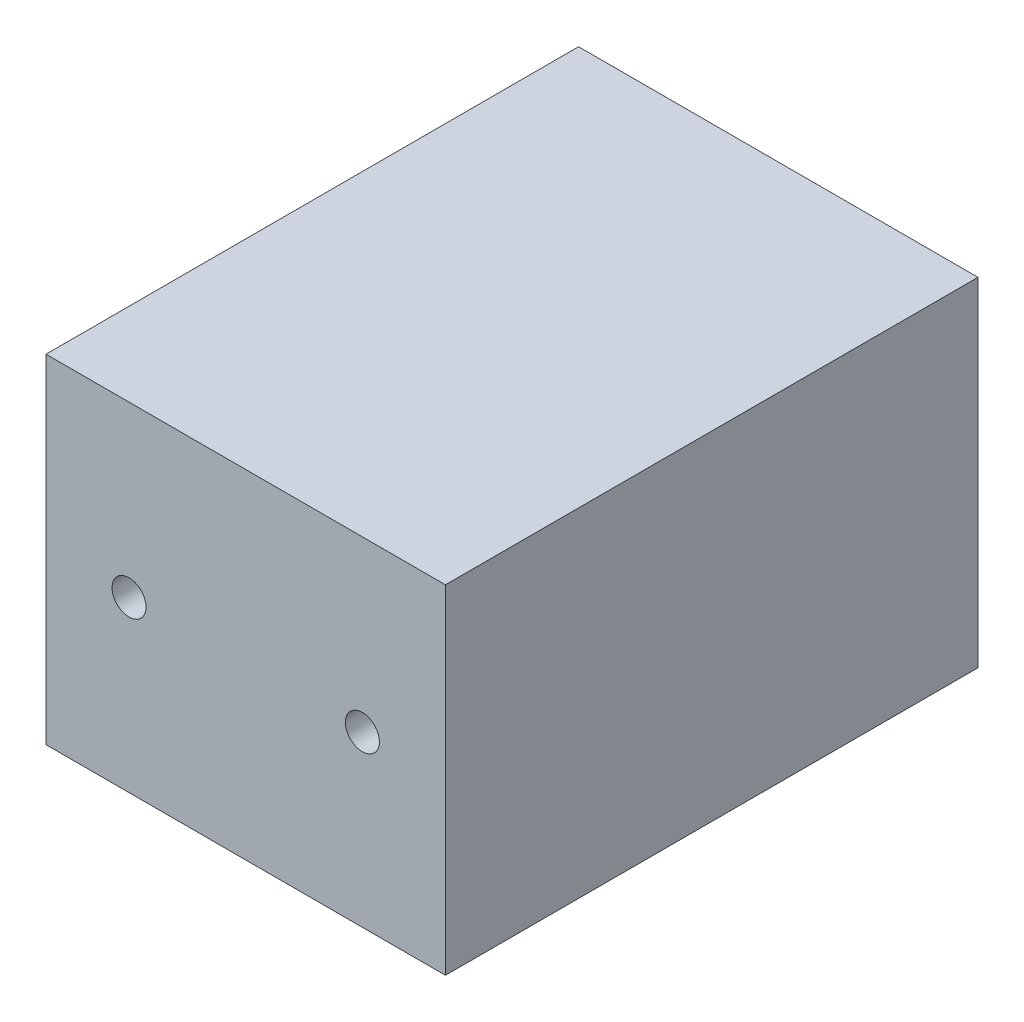
from build123d import *

# Parameters (mm, degrees)
SKETCH1_W               = 60
SKETCH1_H               = 80.00000002
BOSS_EXTRUDE1_DEPTH     = 50.8
F_1_4_20_TAPPED_HOLE1_D = 5.1054


with BuildPart() as part:
    # Sketch1 → Boss-Extrude1 (new body)
    with BuildSketch(Plane(origin=(0, 0, 0), x_dir=(1, 0, 0), z_dir=(0, 1, 0))):
        with Locations((30, 40.00000001)):
            Rectangle(SKETCH1_W, SKETCH1_H)
    extrude(amount=BOSS_EXTRUDE1_DEPTH)

    # 1/4-20 Tapped Hole1 (through all)
    with Locations(Plane(origin=(12.474, 25.4, 0), x_dir=(1, 0, 0), z_dir=(0, 0, 1))):
        with Locations((0, 0), (35.052, 0)):
            Hole(F_1_4_20_TAPPED_HOLE1_D / 2)


solid = part.part
